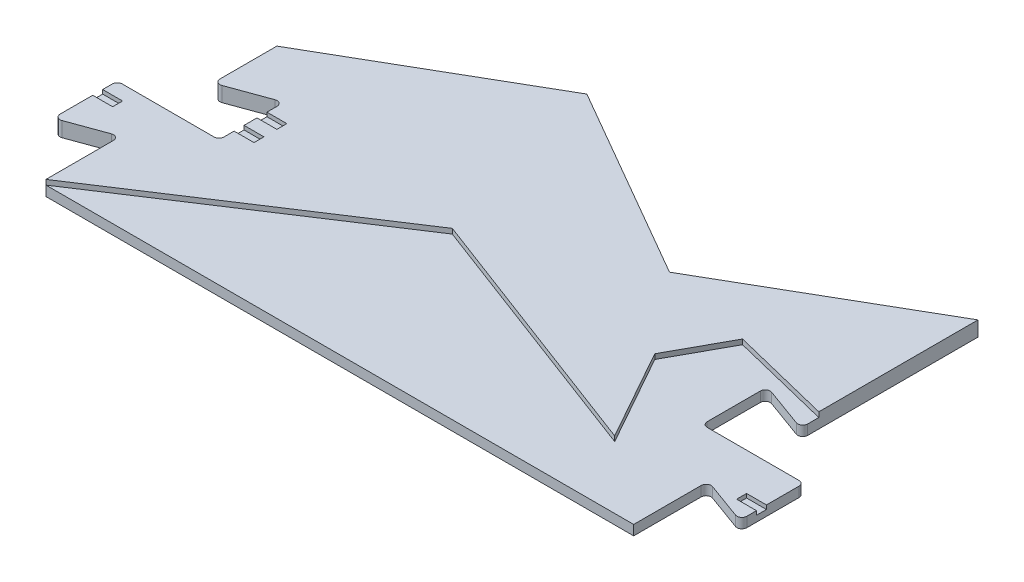
from build123d import *

# Parameters (mm, degrees)
P_IDAT_VYSUNUT_M1_DEPTH  = 3
P_IDAT_VYSUNUT_M2_DEPTH  = 2
ZAOBLIT4_R               = 1
SKICA2_W                 = 4
SKICA2_H                 = 2
ODEBRAT_VYSUNUT_M2_DEPTH = 0.8
SKICA3_W                 = 4
SKICA3_H                 = 2
ODEBRAT_VYSUNUT_M3_DEPTH = 0.8


with BuildPart() as part:
    # Skica1 → P_idat vysunut_m1 (new body)
    with BuildSketch(Plane(origin=(0, 0, 0), x_dir=(1, 0, 0), z_dir=(0, 1, 0))):
        Polygon((-118.143750166, 15), (-118.143750166, 0), (-68.779346971, 32.313398106), (-16.32734533, 12.51119421), (-26.593132493, 30.830954414), (-20.343228113, 42.230019956), (0, 37.22), (0, 69.22), (-39.317553332, 46.52), (-78.635106664, 69.22), (-118.143185584, 46.41), (-118.143185584, 33.5570142), (-107.643750166, 37.378496169), (-107.643750166, 24.278496169), (-128.093750166, 24.278496169), (-128.093750166, 11.378496169), align=None)
    extrude(amount=P_IDAT_VYSUNUT_M1_DEPTH)

    # Skica1_5 → P_idat vysunut_m2 (add)
    with BuildSketch(Plane(origin=(0, 0, 0), x_dir=(1, 0, 0), z_dir=(0, 1, 0))):
        Polygon((-68.779346971, 32.313398106), (-118.143750166, 0), (0, 0), (0, 15), (9.950504516, 11.37831254), (9.950504516, 24.27831254), (-10.5, 24.27831254), (-10.5, 37.37831254), (0, 33.55662508), (0, 37.22), (-20.343228113, 42.230019956), (-26.593132493, 30.830954414), (-16.32734533, 12.51119421), align=None)
    extrude(amount=P_IDAT_VYSUNUT_M2_DEPTH)

    # Zaoblit4
    zaoblit4_edges = [part.edges().sort_by_distance(p)[0] for p in [
        (0, 1, -33.55662508),
        (-10.5, 1, -24.27831254),
        (-10.5, 1, -37.37831254),
        (0, 1, -15),
        (9.950504516, 1, -11.37831254),
        (9.950504516, 1, -24.27831254),
        (-128.093750166, 1.5, -11.378496169),
        (-128.093750166, 1.5, -24.278496169),
        (-107.643750166, 1.5, -24.278496169),
        (-107.643750166, 1.5, -37.378496169),
        (-118.143185584, 1.5, -33.5570142),
        (-118.143750166, 1.5, -15),
    ]]
    fillet(zaoblit4_edges, radius=ZAOBLIT4_R)

    # Skica2 → Odebrat vysunut_m2 (cut)
    with BuildSketch(Plane(origin=(0, 3, 0), x_dir=(1, 0, 0), z_dir=(0, 1, 0))):
        with Locations((-105.643750166, 32.914422166)):
            Rectangle(SKICA2_W, SKICA2_H)
        with Locations((-126.093750166, 20.342570172)):
            Rectangle(SKICA2_W, SKICA2_H)
        with Locations((-105.643750166, 28.314422166)):
            Rectangle(SKICA2_W, SKICA2_H)
    extrude(amount=-ODEBRAT_VYSUNUT_M2_DEPTH, mode=Mode.SUBTRACT)

    # Skica3 → Odebrat vysunut_m3 (cut)
    with BuildSketch(Plane(origin=(0, 2, 0), x_dir=(1, 0, 0), z_dir=(0, 1, 0))):
        with Locations((7.950504516, 15.742386544)):
            Rectangle(SKICA3_W, SKICA3_H)
    extrude(amount=-ODEBRAT_VYSUNUT_M3_DEPTH, mode=Mode.SUBTRACT)


solid = part.part
